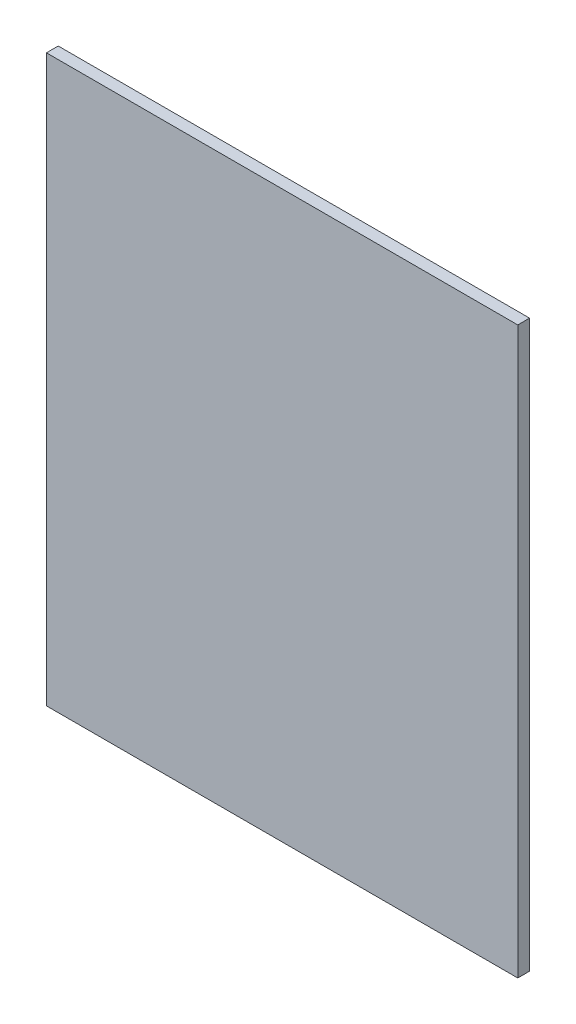
from build123d import *

# Parameters (mm, degrees)
SKETCH1_W      = 400
SKETCH1_H      = 480
EXTRUDE1_DEPTH = 10


with BuildPart() as part:
    # Sketch1 → Extrude1 (new body)
    with BuildSketch(Plane.XY):
        with Locations((140.368216895, -205.537743176)):
            Rectangle(SKETCH1_W, SKETCH1_H)
    extrude(amount=EXTRUDE1_DEPTH)


solid = part.part
